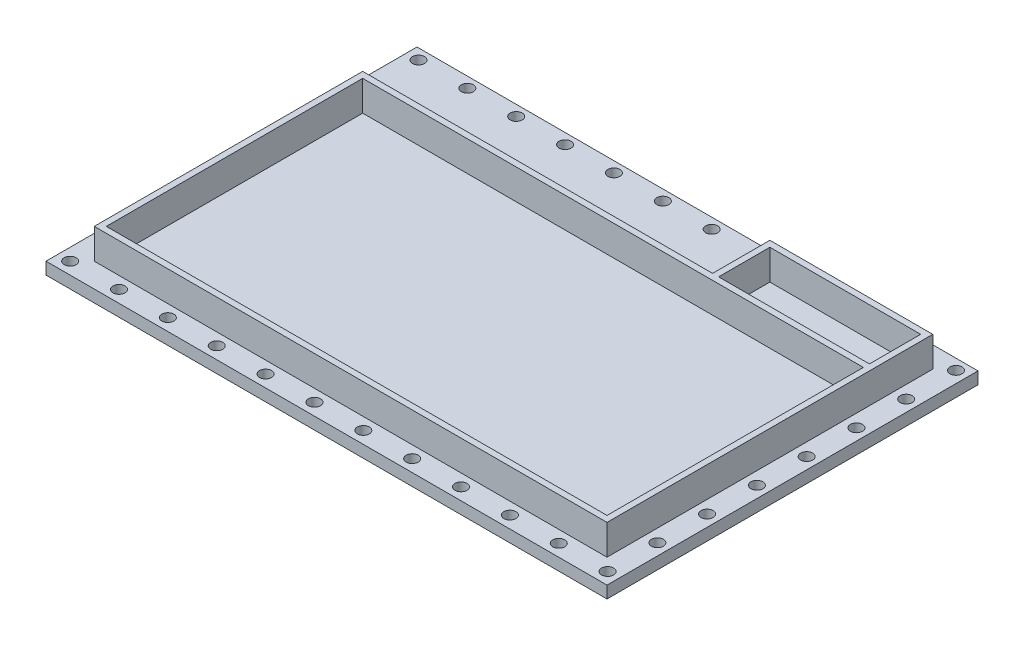
from build123d import *

# Parameters (mm, degrees)
SKETCH1_W           = 166
SKETCH1_H           = 85
SKETCH1_W_2         = 50
SKETCH1_H_2         = 17
BOSS_EXTRUDE4_DEPTH = 10
SKETCH2_W           = 186
SKETCH2_H           = 123
BOSS_EXTRUDE5_DEPTH = 4
SKETCH3_R           = 2
CUT_EXTRUDE2_DEPTH  = 4


with BuildPart() as part:
    # Sketch1 → Boss-Extrude4 (new body)
    with BuildSketch(Plane(origin=(0, 0, 0), x_dir=(1, 0, 0), z_dir=(0, 1, 0))):
        Polygon((0, 89), (116, 89), (116, 108), (170, 108), (170, 89), (170, 0), (0, 0), align=None)
        with Locations((85, 44.5)):
            Rectangle(SKETCH1_W, SKETCH1_H, mode=Mode.SUBTRACT)
        with Locations((143, 97.5)):
            Rectangle(SKETCH1_W_2, SKETCH1_H_2, mode=Mode.SUBTRACT)
    extrude(amount=BOSS_EXTRUDE4_DEPTH)

    # Sketch2 → Boss-Extrude5 (add)
    with BuildSketch(Plane.XZ):
        with Locations((85, -53.5)):
            Rectangle(SKETCH2_W, SKETCH2_H)
    extrude(amount=BOSS_EXTRUDE5_DEPTH)

    # Sketch3 → Cut-Extrude2 (cut)
    with BuildSketch(Plane(origin=(0, 0, 0), x_dir=(1, 0, 0), z_dir=(0, 1, 0))):
        with Locations((-4, -4)):
            Circle(SKETCH3_R)
        with Locations((12.2, -4)):
            Circle(SKETCH3_R)
        with Locations((28.4, -4)):
            Circle(SKETCH3_R)
        with Locations((44.6, -4)):
            Circle(SKETCH3_R)
        with Locations((60.8, -4)):
            Circle(SKETCH3_R)
        with Locations((77, -4)):
            Circle(SKETCH3_R)
        with Locations((93.2, -4)):
            Circle(SKETCH3_R)
        with Locations((109.4, -4)):
            Circle(SKETCH3_R)
        with Locations((125.6, -4)):
            Circle(SKETCH3_R)
        with Locations((141.8, -4)):
            Circle(SKETCH3_R)
        with Locations((158, -4)):
            Circle(SKETCH3_R)
        with Locations((174.2, -4)):
            Circle(SKETCH3_R)
        with Locations((174.2, 12.5)):
            Circle(SKETCH3_R)
        with Locations((174.2, 29)):
            Circle(SKETCH3_R)
        with Locations((174.2, 45.5)):
            Circle(SKETCH3_R)
        with Locations((174.2, 62)):
            Circle(SKETCH3_R)
        with Locations((174.2, 78.5)):
            Circle(SKETCH3_R)
        with Locations((174.2, 95)):
            Circle(SKETCH3_R)
        with Locations((12.2, 111.5)):
            Circle(SKETCH3_R)
        with Locations((28.4, 111.5)):
            Circle(SKETCH3_R)
        with Locations((44.6, 111.5)):
            Circle(SKETCH3_R)
        with Locations((60.8, 111.5)):
            Circle(SKETCH3_R)
        with Locations((77, 111.5)):
            Circle(SKETCH3_R)
        with Locations((93.2, 111.5)):
            Circle(SKETCH3_R)
        with Locations((109.4, 111.5)):
            Circle(SKETCH3_R)
        with Locations((125.6, 111.5)):
            Circle(SKETCH3_R)
        with Locations((141.8, 111.5)):
            Circle(SKETCH3_R)
        with Locations((158, 111.5)):
            Circle(SKETCH3_R)
        with Locations((174.2, 111.5)):
            Circle(SKETCH3_R)
        with Locations((-4, 12.5)):
            Circle(SKETCH3_R)
        with Locations((-4, 29)):
            Circle(SKETCH3_R)
        with Locations((-4, 45.5)):
            Circle(SKETCH3_R)
        with Locations((-4, 62)):
            Circle(SKETCH3_R)
        with Locations((-4, 78.5)):
            Circle(SKETCH3_R)
        with Locations((-4, 95)):
            Circle(SKETCH3_R)
        with Locations((-4, 111.5)):
            Circle(SKETCH3_R)
    extrude(amount=-CUT_EXTRUDE2_DEPTH, mode=Mode.SUBTRACT)


solid = part.part
